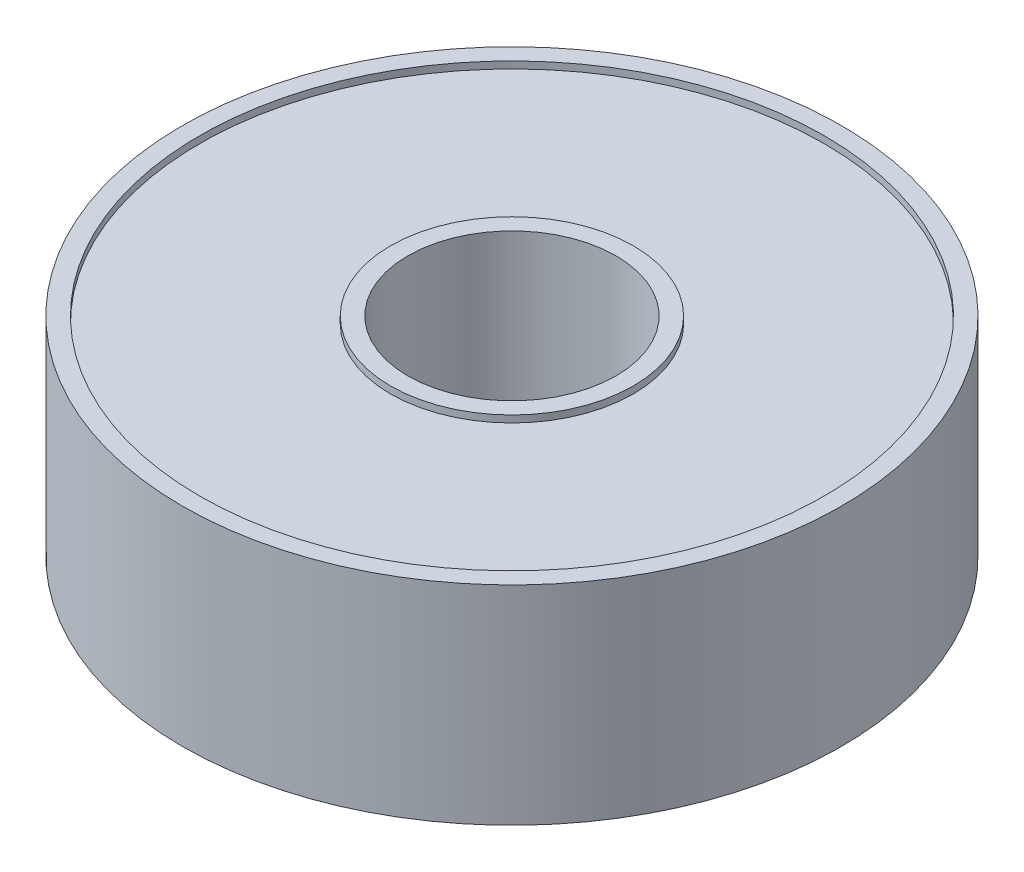
from build123d import *

# Parameters (mm, degrees)
BOSS_EXTRU_1_DEPTH        = 3
BOSS_EXTRU_1_DEPTH_BACK   = 3
ESQUISSE1_R               = 3.5
ESQUISSE1_R_2             = 3
BOSS_EXTRU_1_2_DEPTH      = 3
BOSS_EXTRU_1_2_DEPTH_BACK = 3
ESQUISSE1_R_3             = 9.5
ESQUISSE1_R_4             = 9
BOSS_EXTRU_2_DEPTH        = 2.8
BOSS_EXTRU_2_DEPTH_BACK   = 2.8
ESQUISSE1_6_R             = 9
ESQUISSE1_6_R_2           = 3.5


with BuildPart() as part:
    # Esquisse1 → Boss.-Extru.1 (new, two sides: drawn at the far end of the back side and taken through both)
    with BuildSketch(Plane(origin=(0, 0, 0), x_dir=(1, 0, 0), z_dir=(0, 1, 0)).offset(-BOSS_EXTRU_1_DEPTH_BACK)):
        Circle(ESQUISSE1_R)
        Circle(ESQUISSE1_R_2, mode=Mode.SUBTRACT)
    extrude(amount=BOSS_EXTRU_1_DEPTH + BOSS_EXTRU_1_DEPTH_BACK)



with BuildPart() as body_2:
    # Esquisse1 → Boss.-Extru.1 2 (new, two sides: drawn at the far end of the back side and taken through both)
    with BuildSketch(Plane(origin=(0, 0, 0), x_dir=(1, 0, 0), z_dir=(0, 1, 0)).offset(-BOSS_EXTRU_1_2_DEPTH_BACK)):
        Circle(ESQUISSE1_R_3)
        Circle(ESQUISSE1_R_4, mode=Mode.SUBTRACT)
    extrude(amount=BOSS_EXTRU_1_2_DEPTH + BOSS_EXTRU_1_2_DEPTH_BACK)


with BuildPart() as part_1:
    add(part.part)

    add(body_2.part)  # Boss.-Extru.2 merges body 2
    # Esquisse1_6 → Boss.-Extru.2 (add, two sides: drawn at the far end of the back side and taken through both)
    with BuildSketch(Plane(origin=(0, 0, 0), x_dir=(1, 0, 0), z_dir=(0, 1, 0)).offset(-BOSS_EXTRU_2_DEPTH_BACK)):
        Circle(ESQUISSE1_6_R)
        Circle(ESQUISSE1_6_R_2, mode=Mode.SUBTRACT)
    extrude(amount=BOSS_EXTRU_2_DEPTH + BOSS_EXTRU_2_DEPTH_BACK)


solid = part_1.part
